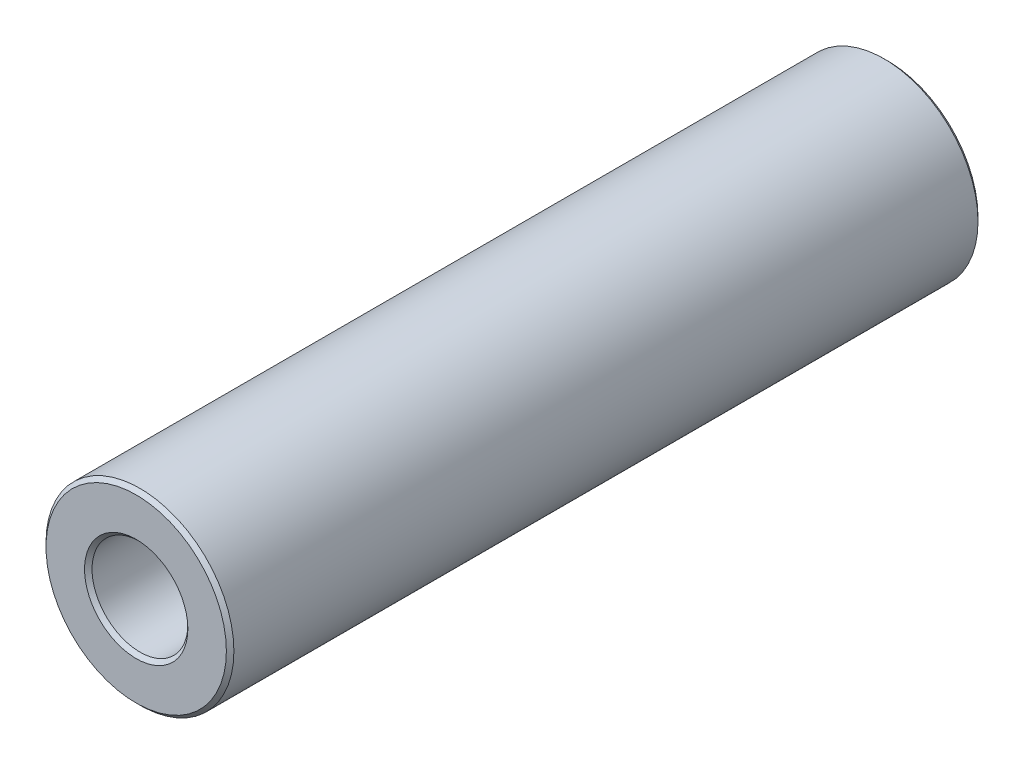
from build123d import *

# Parameters (mm, degrees)
SKETCH1_R           = 5
SKETCH1_R_2         = 2.55
BOSS_EXTRUDE1_DEPTH = 40
CHAMFER1_SIZE       = 0.2


with BuildPart() as part:
    # Sketch1 → Boss-Extrude1 (new body)
    with BuildSketch(Plane.XY):
        Circle(SKETCH1_R)
        Circle(SKETCH1_R_2, mode=Mode.SUBTRACT)
    extrude(amount=BOSS_EXTRUDE1_DEPTH)

    # Chamfer1
    chamfer1_edges = [part.edges().sort_by_distance(p)[0] for p in [
        (-5, 0, 0),
        (-5, 0, 40),
        (-2.55, 0, 0),
        (-2.55, 0, 40),
    ]]
    chamfer(chamfer1_edges, length=CHAMFER1_SIZE)


solid = part.part
